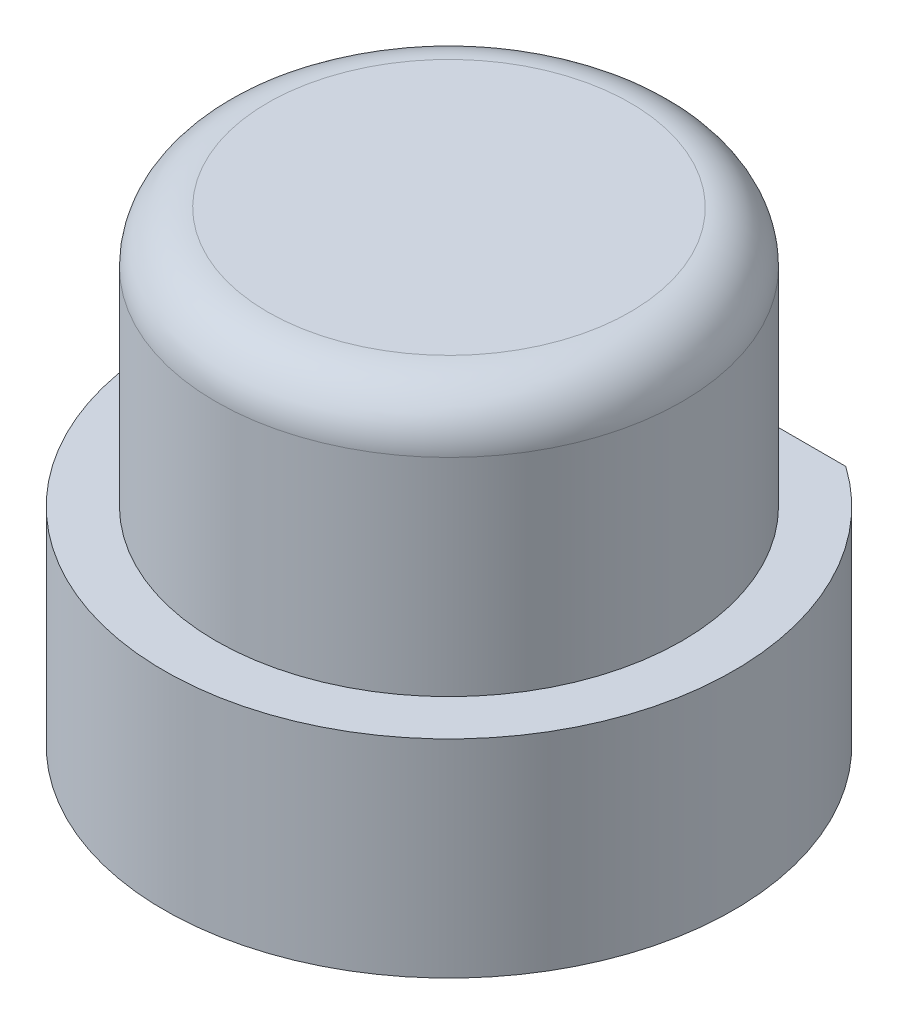
from build123d import *

# Parameters (mm, degrees)
Y_KSEKLIK_EKSTR_ZYON1_DEPTH = 9
IZIM2_R                     = 3.5
KES_EKSTR_ZYON1_DEPTH       = 1.5
IZIM3_R                     = 6
IZIM3_R_2                   = 4.5
KES_EKSTR_ZYON2_DEPTH       = 5
RADYUS1_R                   = 1


with BuildPart() as part:
    # Çizim1 → Yükseklik-Ekstrüzyon1 (new body)
    with BuildSketch(Plane(origin=(0, 0, 0), x_dir=(1, 0, 0), z_dir=(0, 1, 0))):
        with BuildLine():
            Line((3.16227766, 4.5), (-3.16227766, 4.5))
            ThreePointArc((-3.16227766, 4.5), (0, -5.5), (3.16227766, 4.5))
        make_face()
    extrude(amount=Y_KSEKLIK_EKSTR_ZYON1_DEPTH)

    # Çizim2 → Kes-Ekstrüzyon1 (cut)
    with BuildSketch(Plane.XZ):
        Circle(IZIM2_R)
    extrude(amount=-KES_EKSTR_ZYON1_DEPTH, mode=Mode.SUBTRACT)

    # Çizim3 → Kes-Ekstrüzyon2 (cut)
    with BuildSketch(Plane(origin=(0, 9, 0), x_dir=(1, 0, 0), z_dir=(0, 1, 0))):
        Circle(IZIM3_R)
        Circle(IZIM3_R_2, mode=Mode.SUBTRACT)
    extrude(amount=-KES_EKSTR_ZYON2_DEPTH, mode=Mode.SUBTRACT)

    # Radyus1
    radyus1_edges = [part.edges().sort_by_distance(p)[0] for p in [
        (-4.5, 9, 0),
    ]]
    fillet(radyus1_edges, radius=RADYUS1_R)


solid = part.part
